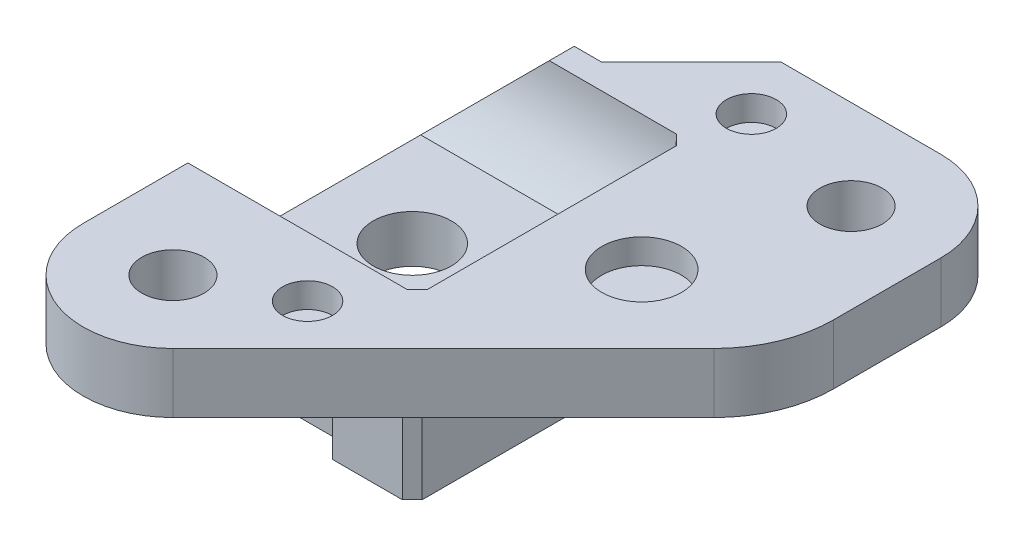
from build123d import *

# Parameters (mm, degrees)
SKETCH1_R                = 1.5625
BOSS_EXTRUDE1_DEPTH      = 3
SKETCH2_R                = 1.96
BOSS_EXTRUDE2_DEPTH      = 4
BOSS_EXTRUDE2_DEPTH_BACK = 3
CUT_EXTRUDE1_DEPTH       = 11.5
CHAMFER1_SIZE            = 0.5
CUT_EXTRUDE3_DEPTH       = 4.7625
FILLET1_R                = 6
SKETCH6_R                = 2
SKETCH6_R_2              = 1.25
CUT_EXTRUDE4_DEPTH       = 1.25


with BuildPart() as part:
    # Sketch1 → Boss-Extrude1 (new body)
    with BuildSketch(Plane(origin=(0, 0, 0), x_dir=(1, 0, 0), z_dir=(0, 1, 0))):
        with BuildLine():
            Line((3.181980515, -15.181980515), (18.5, 0.136038969))
            Line((18.5, 0.136038969), (18.5, 8))
            ThreePointArc((18.5, 8), (17.181980515, 11.181980515), (14, 12.5))
            Line((14, 12.5), (6, 12.5))
            Line((6, 12.5), (1, 7.5))
            Line((1, 7.5), (-4.5, 2))
            Line((-4.5, 2), (-4.5, -6.5))
            Line((-4.5, -6.5), (-4.5, -12))
            ThreePointArc((-4.5, -12), (-1.722075446, -16.157457896), (3.181980515, -15.181980515))
        make_face()
        with Locations((0, -12)):
            Circle(SKETCH1_R, mode=Mode.SUBTRACT)
        with Locations((14, 8)):
            Circle(SKETCH1_R, mode=Mode.SUBTRACT)
    extrude(amount=BOSS_EXTRUDE1_DEPTH)

    # Sketch2 → Boss-Extrude2 (add, two sides)
    with BuildSketch(Plane.XZ) as boss_extrude2_sk:
        Polygon((9, -9), (5, -9), (5, -8), (-4.5, -8), (-4.5, 8), (5, 8), (5, 9), (9, 9), align=None)
        Circle(SKETCH2_R, mode=Mode.SUBTRACT)
    extrude(amount=BOSS_EXTRUDE2_DEPTH)
    extrude(boss_extrude2_sk.sketch, amount=-BOSS_EXTRUDE2_DEPTH_BACK)

    # Sketch3 → Cut-Extrude1 (cut)
    with BuildSketch(Plane.ZY.offset(4.5)):
        with BuildLine():
            Line((-4.921188881, -1.62), (4.921188881, -1.62))
            ThreePointArc((4.921188881, -1.62), (6.276166224, 0.515601174), (6.75, 3))
            Line((6.75, 3), (-6.75, 3))
            ThreePointArc((-6.75, 3), (-6.276166224, 0.515601174), (-4.921188881, -1.62))
        make_face()
    extrude(amount=-CUT_EXTRUDE1_DEPTH, mode=Mode.SUBTRACT)

    # Chamfer1
    chamfer1_edges = [part.edges().sort_by_distance(p)[0] for p in [
        (9, -2, 9),
        (9, -2, -9),
        (7, -1.62, 0),
        (7, 0.515601174, -6.276166224),
        (7, 0.515601174, 6.276166224),
    ]]
    chamfer(chamfer1_edges, length=CHAMFER1_SIZE)

    # Sketch5 → Cut-Extrude3 (cut)
    with BuildSketch(Plane(origin=(0, 0, -8), x_dir=(-1, 0, 0), z_dir=(0, 0, -1))):
        Polygon((4.5, -1.62), (-0.12, 3), (4.5, 3), align=None)
    extrude(amount=-CUT_EXTRUDE3_DEPTH, mode=Mode.SUBTRACT)

    # Fillet1
    fillet1_edges = [part.edges().sort_by_distance(p)[0] for p in [
        (18.5, 1.5, -0.136038969),
    ]]
    fillet(fillet1_edges, radius=FILLET1_R)

    # Sketch6 → Cut-Extrude4 (cut)
    with BuildSketch(Plane(origin=(0, 3, 0), x_dir=(1, 0, 0), z_dir=(0, 1, 0))):
        with Locations((11.5, 0)):
            Circle(SKETCH6_R)
        with Locations((4.5, -9.75)):
            Circle(SKETCH6_R_2)
        with Locations((7.5, 9.5)):
            Circle(SKETCH6_R_2)
    extrude(amount=-CUT_EXTRUDE4_DEPTH, mode=Mode.SUBTRACT)


solid = part.part
